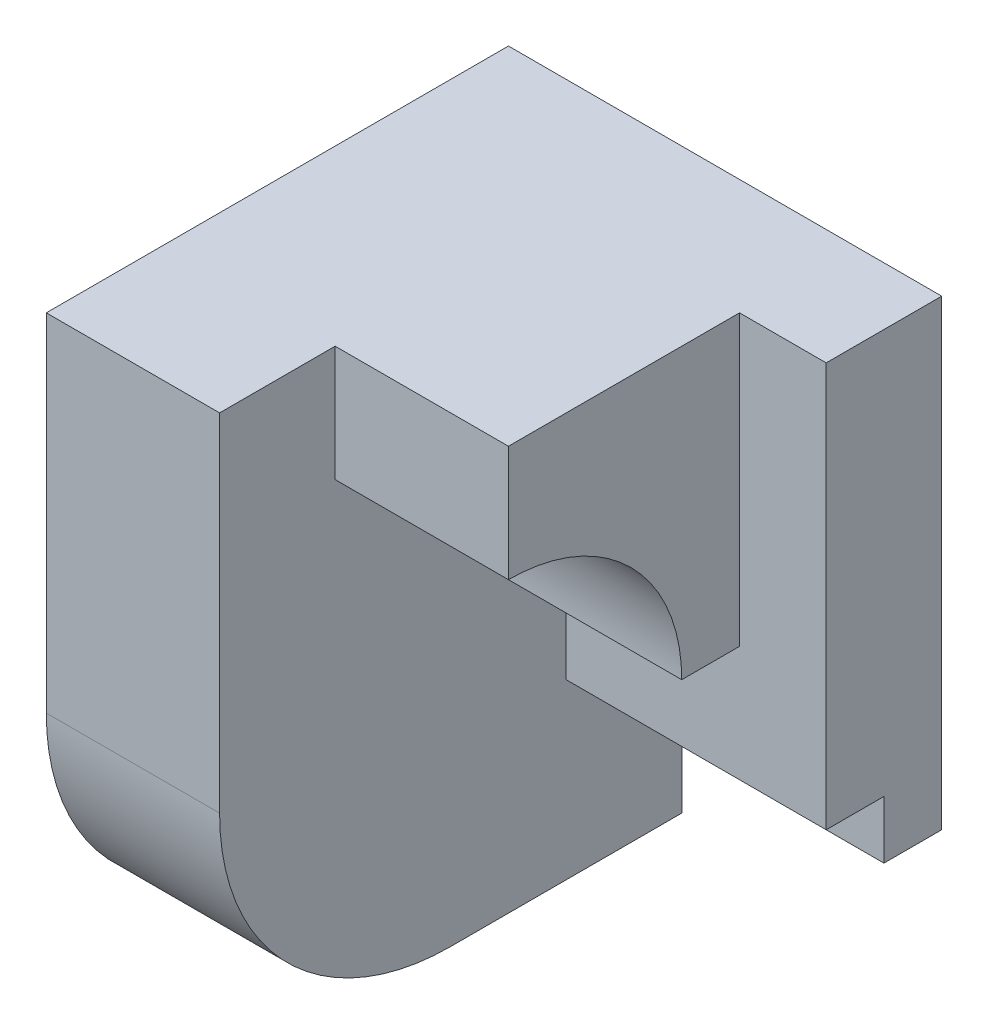
from build123d import *

# Parameters (mm, degrees)
BOSS_EXTRUDE1_DEPTH = 3
BOSS_EXTRUDE2_DEPTH = 4.5
BOSS_EXTRUDE3_DEPTH = 3


with BuildPart() as part:
    # Sketch1 → Boss-Extrude1 (new body)
    with BuildSketch(Plane(origin=(0, 0, 0), x_dir=(0, 0, -1), z_dir=(1, 0, 0))):
        with BuildLine():
            Line((4, -5), (0, -5))
            ThreePointArc((0, -5), (-2.828427125, -3.828427125), (-4, -1))
            Line((-4, -1), (-4, 5))
            Line((-4, 5), (4, 5))
            Line((4, 5), (4, -5))
        make_face()
    extrude(amount=BOSS_EXTRUDE1_DEPTH)

    # Sketch2 → Boss-Extrude2 (add)
    with BuildSketch(Plane(origin=(3, 0, 0), x_dir=(0, 0, -1), z_dir=(1, 0, 0))):
        Polygon((4, -3), (4, 5), (2, 5), (2, -2), (3, -2), (3, -3), align=None)
    extrude(amount=BOSS_EXTRUDE2_DEPTH)

    # Sketch3 → Boss-Extrude3 (add)
    with BuildSketch(Plane(origin=(3, 0, 0), x_dir=(0, 0, -1), z_dir=(1, 0, 0))):
        with BuildLine():
            Line((2, 0), (2, 5))
            Line((2, 5), (-2, 5))
            Line((-2, 5), (-2, 3))
            ThreePointArc((-2, 3), (0.121320344, 2.121320344), (1, 0))
            Line((1, 0), (2, 0))
        make_face()
    extrude(amount=BOSS_EXTRUDE3_DEPTH)


solid = part.part
